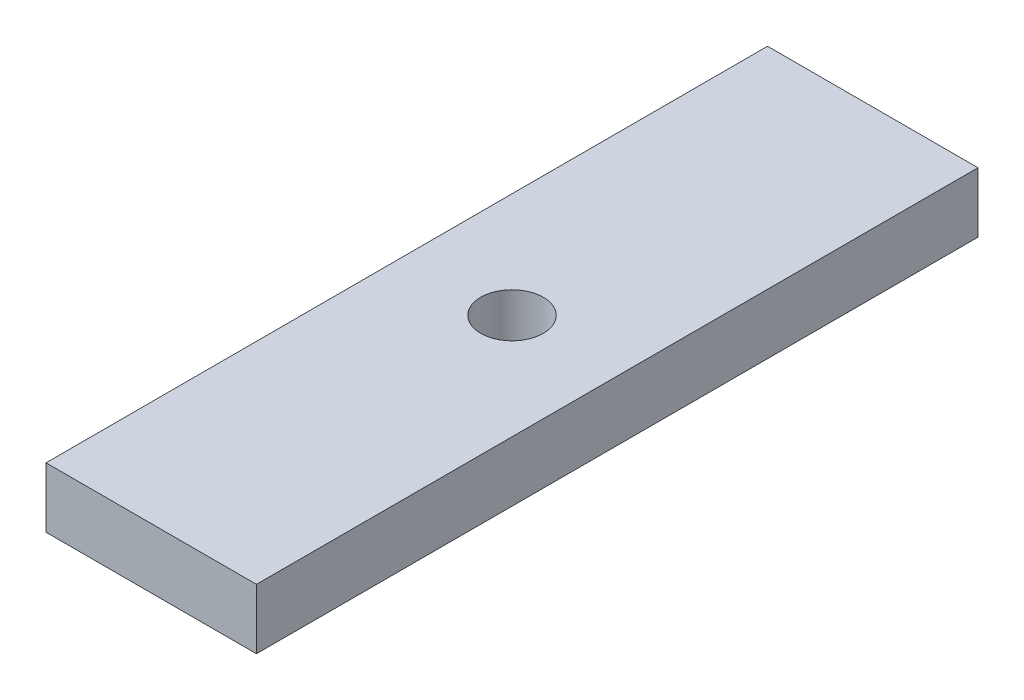
from build123d import *

# Parameters (mm, degrees)
BOSS_EXTRUDE1_DEPTH = 10


with BuildPart() as part:
    # Sketch1 → Boss-Extrude1 (new body)
    with BuildSketch(Plane(origin=(0, 0, 0), x_dir=(1, 0, 0), z_dir=(0, 1, 0))):
        with BuildLine():
            Line((0, 120), (0, 60))
            Line((0, 60), (12.294200791, 60))
            ThreePointArc((12.294200791, 60), (17.5, 65.205799209), (22.705799209, 60))
            Line((22.705799209, 60), (35, 60))
            Line((35, 60), (35, 120))
            Line((35, 120), (0, 120))
        make_face()
        with BuildLine():
            Line((0, 60), (0, 0))
            Line((0, 0), (35, 0))
            Line((35, 0), (35, 60))
            Line((35, 60), (22.705799209, 60))
            ThreePointArc((22.705799209, 60), (17.5, 54.794200791), (12.294200791, 60))
            Line((12.294200791, 60), (0, 60))
        make_face()
    extrude(amount=BOSS_EXTRUDE1_DEPTH)


solid = part.part
